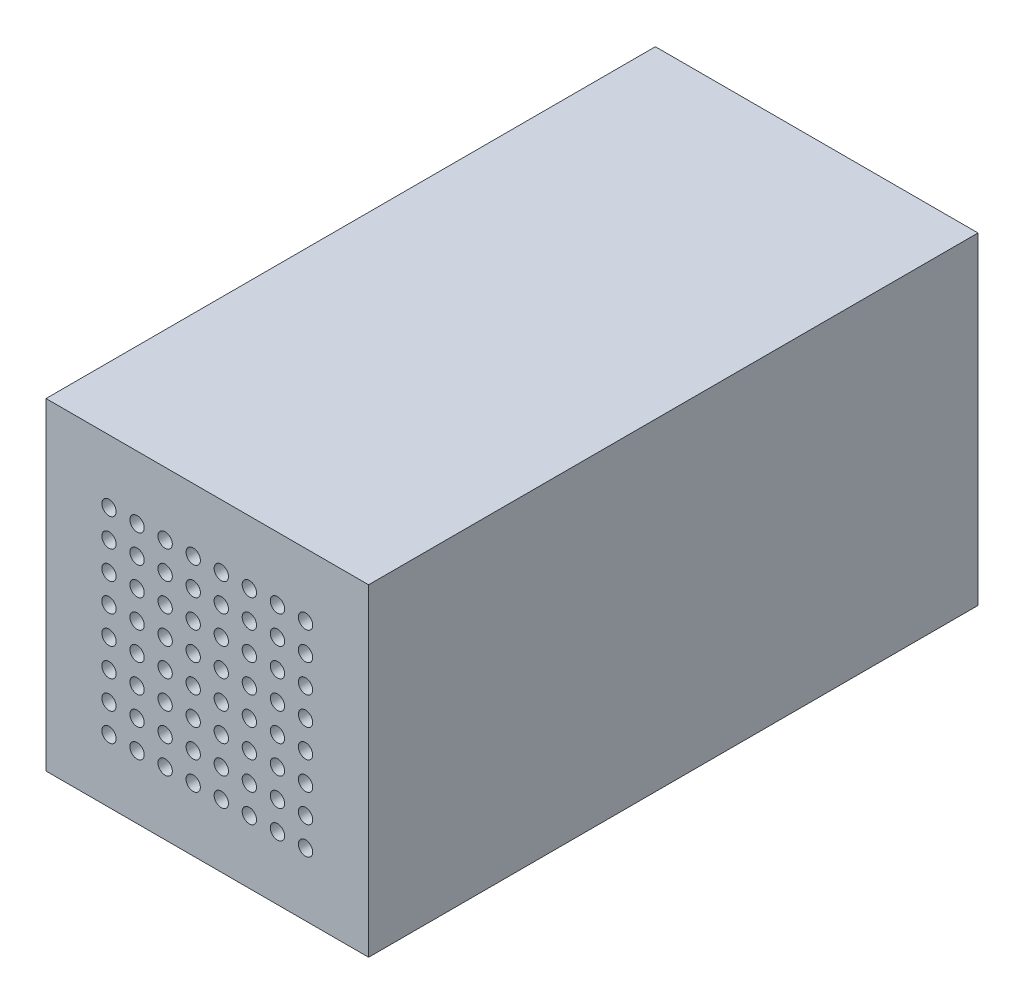
from build123d import *

# Parameters (mm, degrees)
SKETCH2_W           = 27
SKETCH2_H           = 27
BOSS_EXTRUDE1_DEPTH = 8
SKETCH5_R           = 0.6
CUT_EXTRUDE2_DEPTH  = 8
SKETCH2_6_W         = 27
SKETCH2_6_H         = 27
SKETCH2_6_W_2       = 20
SKETCH2_6_H_2       = 20
BOSS_EXTRUDE2_DEPTH = 43


with BuildPart() as part:
    # Sketch2 → Boss-Extrude1 (new body)
    with BuildSketch(Plane.XY.offset(43)):
        Rectangle(SKETCH2_W, SKETCH2_H)
    extrude(amount=BOSS_EXTRUDE1_DEPTH)

    # Sketch5 → Cut-Extrude2 (cut)
    with BuildSketch(Plane.XY.offset(43)):
        with Locations((-8.23, 8.23)):
            Circle(SKETCH5_R)
        with Locations((-5.88, 8.23)):
            Circle(SKETCH5_R)
        with Locations((-3.53, 8.23)):
            Circle(SKETCH5_R)
        with Locations((-1.18, 8.23)):
            Circle(SKETCH5_R)
        with Locations((1.17, 8.23)):
            Circle(SKETCH5_R)
        with Locations((3.52, 8.23)):
            Circle(SKETCH5_R)
        with Locations((5.87, 8.23)):
            Circle(SKETCH5_R)
        with Locations((8.22, 8.23)):
            Circle(SKETCH5_R)
        with Locations((-5.88, 5.88)):
            Circle(SKETCH5_R)
        with Locations((-3.53, 5.88)):
            Circle(SKETCH5_R)
        with Locations((-1.18, 5.88)):
            Circle(SKETCH5_R)
        with Locations((1.17, 5.88)):
            Circle(SKETCH5_R)
        with Locations((3.52, 5.88)):
            Circle(SKETCH5_R)
        with Locations((5.87, 5.88)):
            Circle(SKETCH5_R)
        with Locations((8.22, 5.88)):
            Circle(SKETCH5_R)
        with Locations((-5.88, 3.53)):
            Circle(SKETCH5_R)
        with Locations((-3.53, 3.53)):
            Circle(SKETCH5_R)
        with Locations((-1.18, 3.53)):
            Circle(SKETCH5_R)
        with Locations((1.17, 3.53)):
            Circle(SKETCH5_R)
        with Locations((3.52, 3.53)):
            Circle(SKETCH5_R)
        with Locations((5.87, 3.53)):
            Circle(SKETCH5_R)
        with Locations((8.22, 3.53)):
            Circle(SKETCH5_R)
        with Locations((-5.88, 1.18)):
            Circle(SKETCH5_R)
        with Locations((-3.53, 1.18)):
            Circle(SKETCH5_R)
        with Locations((-1.18, 1.18)):
            Circle(SKETCH5_R)
        with Locations((1.17, 1.18)):
            Circle(SKETCH5_R)
        with Locations((3.52, 1.18)):
            Circle(SKETCH5_R)
        with Locations((5.87, 1.18)):
            Circle(SKETCH5_R)
        with Locations((8.22, 1.18)):
            Circle(SKETCH5_R)
        with Locations((-5.88, -1.17)):
            Circle(SKETCH5_R)
        with Locations((-3.53, -1.17)):
            Circle(SKETCH5_R)
        with Locations((-1.18, -1.17)):
            Circle(SKETCH5_R)
        with Locations((1.17, -1.17)):
            Circle(SKETCH5_R)
        with Locations((3.52, -1.17)):
            Circle(SKETCH5_R)
        with Locations((5.87, -1.17)):
            Circle(SKETCH5_R)
        with Locations((8.22, -1.17)):
            Circle(SKETCH5_R)
        with Locations((-5.88, -3.52)):
            Circle(SKETCH5_R)
        with Locations((-3.53, -3.52)):
            Circle(SKETCH5_R)
        with Locations((-1.18, -3.52)):
            Circle(SKETCH5_R)
        with Locations((1.17, -3.52)):
            Circle(SKETCH5_R)
        with Locations((3.52, -3.52)):
            Circle(SKETCH5_R)
        with Locations((5.87, -3.52)):
            Circle(SKETCH5_R)
        with Locations((8.22, -3.52)):
            Circle(SKETCH5_R)
        with Locations((-5.88, -5.87)):
            Circle(SKETCH5_R)
        with Locations((-3.53, -5.87)):
            Circle(SKETCH5_R)
        with Locations((-1.18, -5.87)):
            Circle(SKETCH5_R)
        with Locations((1.17, -5.87)):
            Circle(SKETCH5_R)
        with Locations((3.52, -5.87)):
            Circle(SKETCH5_R)
        with Locations((5.87, -5.87)):
            Circle(SKETCH5_R)
        with Locations((8.22, -5.87)):
            Circle(SKETCH5_R)
        with Locations((-5.88, -8.22)):
            Circle(SKETCH5_R)
        with Locations((-3.53, -8.22)):
            Circle(SKETCH5_R)
        with Locations((-1.18, -8.22)):
            Circle(SKETCH5_R)
        with Locations((1.17, -8.22)):
            Circle(SKETCH5_R)
        with Locations((3.52, -8.22)):
            Circle(SKETCH5_R)
        with Locations((5.87, -8.22)):
            Circle(SKETCH5_R)
        with Locations((8.22, -8.22)):
            Circle(SKETCH5_R)
        with Locations((-8.23, 5.88)):
            Circle(SKETCH5_R)
        with Locations((-8.23, 3.53)):
            Circle(SKETCH5_R)
        with Locations((-8.23, 1.18)):
            Circle(SKETCH5_R)
        with Locations((-8.23, -1.17)):
            Circle(SKETCH5_R)
        with Locations((-8.23, -3.52)):
            Circle(SKETCH5_R)
        with Locations((-8.23, -5.87)):
            Circle(SKETCH5_R)
        with Locations((-8.23, -8.22)):
            Circle(SKETCH5_R)
    extrude(amount=CUT_EXTRUDE2_DEPTH, mode=Mode.SUBTRACT)

    # Sketch2_6 → Boss-Extrude2 (add)
    with BuildSketch(Plane.XY.offset(43)):
        Rectangle(SKETCH2_6_W, SKETCH2_6_H)
        Rectangle(SKETCH2_6_W_2, SKETCH2_6_H_2, mode=Mode.SUBTRACT)
    extrude(amount=-BOSS_EXTRUDE2_DEPTH)


solid = part.part
